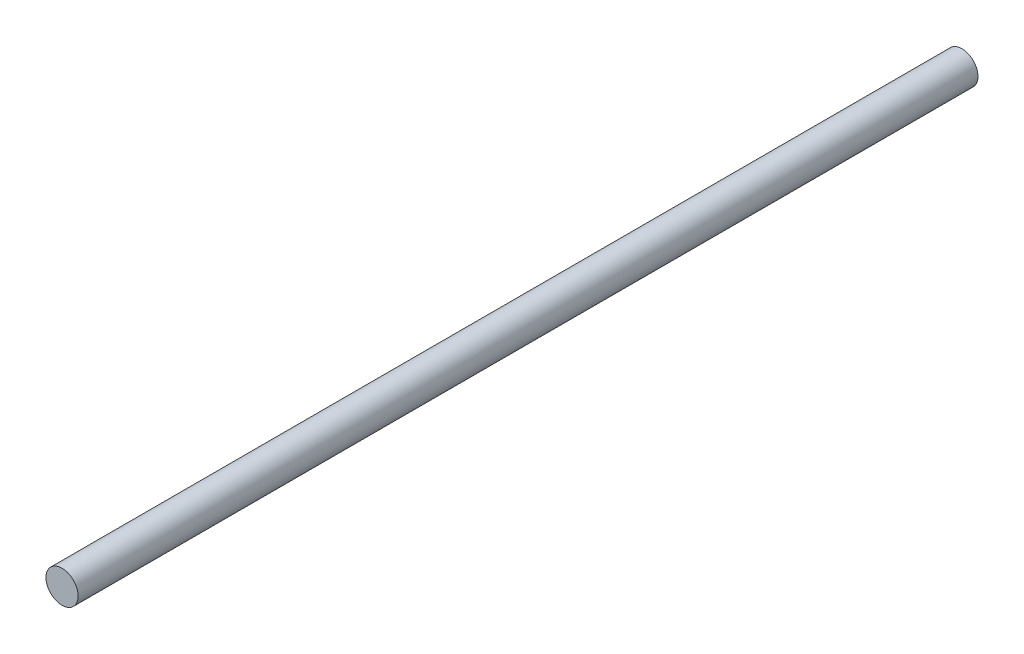
from build123d import *

# Parameters (mm, degrees)
SKETCH1_R           = 3.175
BOSS_EXTRUDE1_DEPTH = 177.8


with BuildPart() as part:
    # Sketch1 → Boss-Extrude1 (new body)
    with BuildSketch(Plane.XY):
        Circle(SKETCH1_R)
    extrude(amount=BOSS_EXTRUDE1_DEPTH)


solid = part.part
